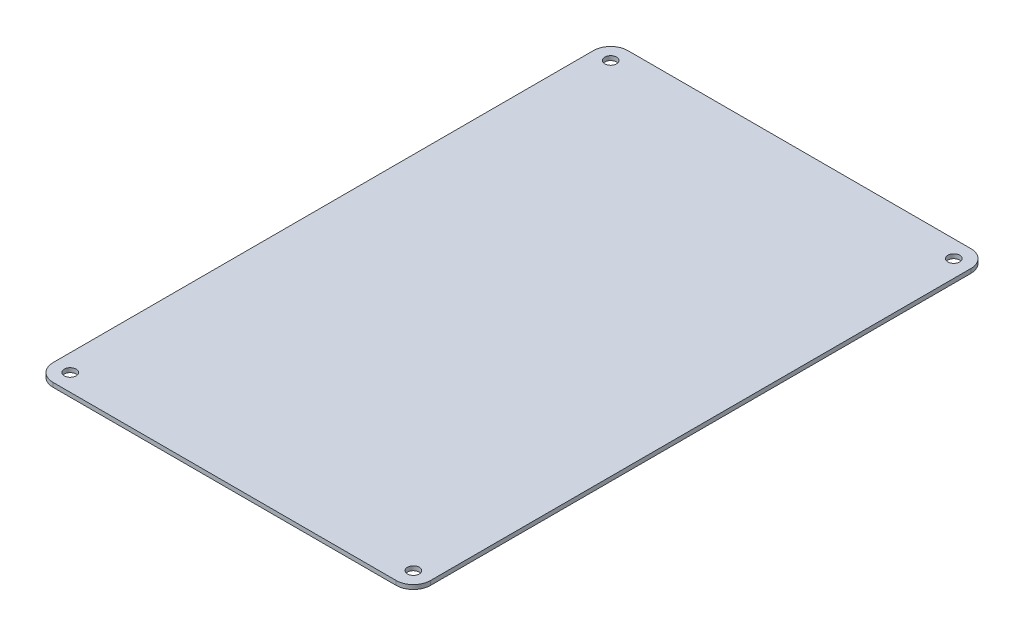
from build123d import *

# Parameters (mm, degrees)
SKETCH1_R           = 2.1828125
BOSS_EXTRUDE1_DEPTH = 0.79375


with BuildPart() as part:
    # Sketch1 → Boss-Extrude1 (new body, symmetric)
    with BuildSketch(Plane(origin=(0, 0, 0), x_dir=(1, 0, 0), z_dir=(0, 1, 0))):
        with BuildLine():
            Line((6.35, 0), (133.35, 0))
            ThreePointArc((133.35, 0), (137.840128061, 1.859871939), (139.7, 6.35))
            Line((139.7, 6.35), (139.7, 206.375))
            ThreePointArc((139.7, 206.375), (137.840128061, 210.865128061), (133.35, 212.725))
            Line((133.35, 212.725), (6.35, 212.725))
            ThreePointArc((6.35, 212.725), (1.859871939, 210.865128061), (0, 206.375))
            Line((0, 206.375), (0, 6.35))
            ThreePointArc((0, 6.35), (1.859871939, 1.859871939), (6.35, 0))
        make_face()
        with Locations((6.35, 206.375)):
            Circle(SKETCH1_R, mode=Mode.SUBTRACT)
        with Locations((133.35, 206.375)):
            Circle(SKETCH1_R, mode=Mode.SUBTRACT)
        with Locations((6.35, 6.35)):
            Circle(SKETCH1_R, mode=Mode.SUBTRACT)
        with Locations((133.35, 6.35)):
            Circle(SKETCH1_R, mode=Mode.SUBTRACT)
    extrude(amount=BOSS_EXTRUDE1_DEPTH, both=True)


solid = part.part
